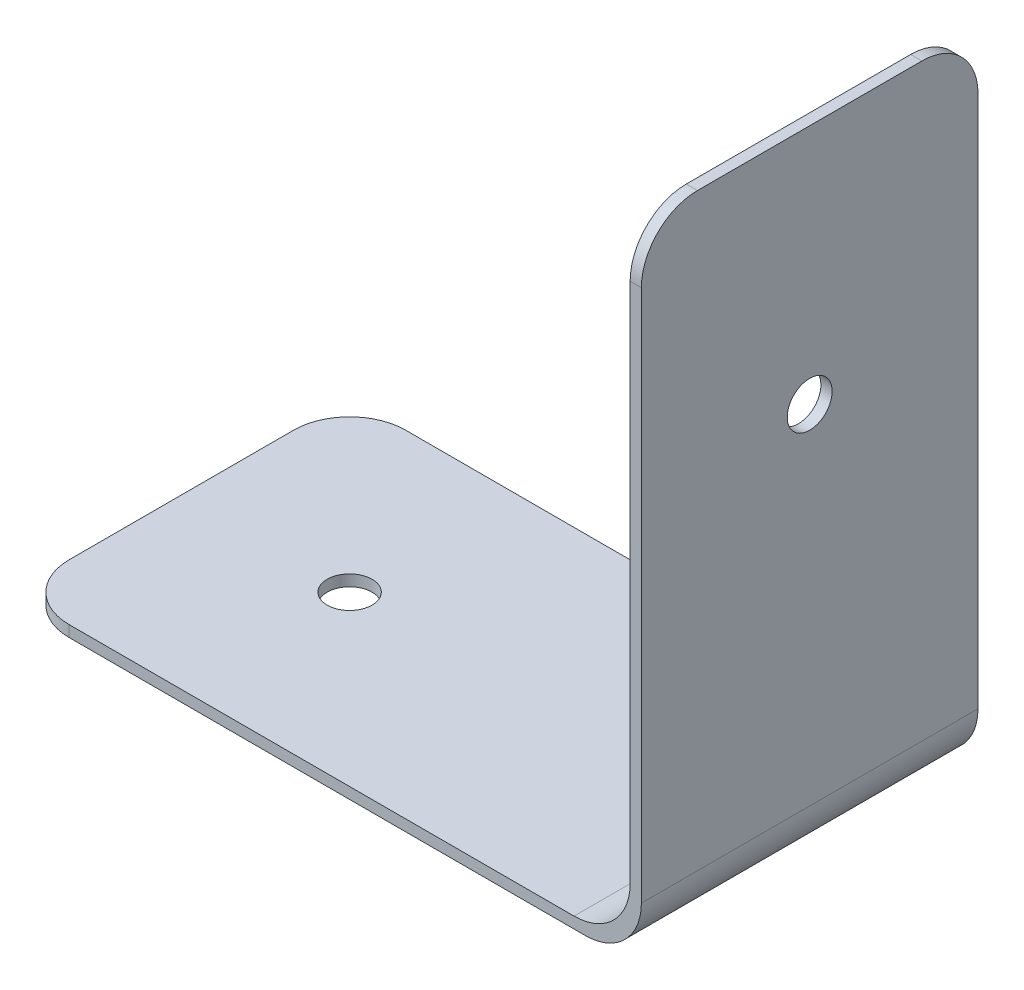
from build123d import *

# Parameters (mm, degrees)
BOSS_EXTRUDE1_DEPTH = 60
SKETCH3_R           = 4
CUT_EXTRUDE1_DEPTH  = 3
SKETCH4_R           = 4
CUT_EXTRUDE2_DEPTH  = 3
FILLET3_R           = 10
FILLET4_R           = 10


with BuildPart() as part:
    # Sketch1 → Boss-Extrude1 (new body)
    with BuildSketch(Plane.XY):
        with BuildLine():
            Line((0, 0), (102, 0))
            ThreePointArc((102, 0), (109.071067812, 2.928932188), (112, 10))
            Line((112, 10), (112, 115))
            Line((112, 115), (110, 115))
            Line((110, 115), (110, 12))
            ThreePointArc((110, 12), (107.071067812, 4.928932188), (100, 2))
            Line((100, 2), (0, 2))
            Line((0, 2), (0, 0))
        make_face()
    extrude(amount=BOSS_EXTRUDE1_DEPTH)

    # Sketch3 → Cut-Extrude1 (cut, through all)
    with BuildSketch(Plane(origin=(0, 2, 0), x_dir=(1, 0, 0), z_dir=(0, 1, 0))):
        with Locations((30, -30)):
            Circle(SKETCH3_R)
    extrude(amount=-CUT_EXTRUDE1_DEPTH, mode=Mode.SUBTRACT)

    # Sketch4 → Cut-Extrude2 (cut, through all)
    with BuildSketch(Plane.ZY.offset(-110)):
        with Locations((30, 72)):
            Circle(SKETCH4_R)
    extrude(amount=-CUT_EXTRUDE2_DEPTH, mode=Mode.SUBTRACT)

    # Fillet3
    fillet3_edges = [part.edges().sort_by_distance(p)[0] for p in [
        (111, 115, 60),
        (111, 115, 0),
    ]]
    fillet(fillet3_edges, radius=FILLET3_R)

    # Fillet4
    fillet4_edges = [part.edges().sort_by_distance(p)[0] for p in [
        (0, 1, 0),
        (0, 1, 60),
    ]]
    fillet(fillet4_edges, radius=FILLET4_R)


solid = part.part
